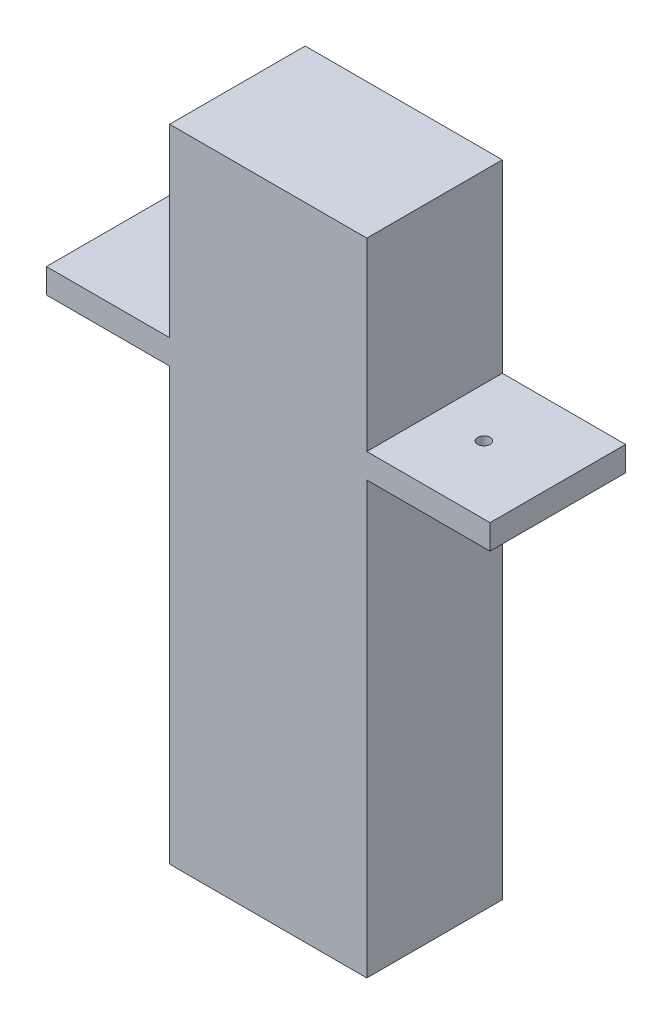
from build123d import *

# Parameters (mm, degrees)
BOSS_EXTRU_1_DEPTH      = 9
ESQUISSE2_W             = 16
ESQUISSE2_H             = 52
BOSS_EXTRU_2_DEPTH      = 2
ESQUISSE5_R             = 1.75
BOSS_EXTRU_5_DEPTH      = 5
ESQUISSE6_R             = 0.5
ENL_V_MAT_EXTRU_1_DEPTH = 5
ESQUISSE11_W            = 11
ESQUISSE11_H            = 2
BOSS_EXTRU_6_DEPTH      = 10
ESQUISSE12_R            = 0.5
ENL_V_MAT_EXTRU_2_DEPTH = 38


with BuildPart() as part:
    # Esquisse1 → Boss.-Extru.1 (new body)
    with BuildSketch(Plane.XY):
        Polygon((-6, -25), (-6, 25), (6, 25), (6, -25), (8, -25), (8, 27), (-8, 27), (-8, -25), align=None)
    extrude(amount=BOSS_EXTRU_1_DEPTH)

    # Esquisse2 → Boss.-Extru.2 (add)
    with BuildSketch(Plane.XY.offset(9)):
        with Locations((0, 1)):
            Rectangle(ESQUISSE2_W, ESQUISSE2_H)
    extrude(amount=BOSS_EXTRU_2_DEPTH)

    # Esquisse5 → Boss.-Extru.5 (add)
    with BuildSketch(Plane(origin=(0, 0, 9), x_dir=(-1, 0, 0), z_dir=(0, 0, -1))):
        with Locations((0, 4)):
            Circle(ESQUISSE5_R)
    extrude(amount=BOSS_EXTRU_5_DEPTH)

    # Esquisse6 → Enlèv. mat.-Extru.1 (cut)
    with BuildSketch(Plane(origin=(0, 0, 4), x_dir=(-1, 0, 0), z_dir=(0, 0, -1))):
        with Locations((0, 4)):
            Circle(ESQUISSE6_R)
    extrude(amount=-ENL_V_MAT_EXTRU_1_DEPTH, mode=Mode.SUBTRACT)

    # Esquisse11 → Boss.-Extru.6 (add)
    with BuildSketch(Plane.ZY.offset(8)):
        with Locations((5.5, 11)):
            Rectangle(ESQUISSE11_W, ESQUISSE11_H)
    boss_extru_6 = extrude(amount=BOSS_EXTRU_6_DEPTH)

    # Esquisse12 → Enlèv. mat.-Extru.2 (cut, through all)
    with BuildSketch(Plane(origin=(0, 12, 0), x_dir=(1, 0, 0), z_dir=(0, 1, 0))):
        with Locations((-12, -5.5)):
            Circle(ESQUISSE12_R)
    enl_v_mat_extru_2 = extrude(amount=-ENL_V_MAT_EXTRU_2_DEPTH, mode=Mode.SUBTRACT)

    # Symétrie1: Boss.-Extru.6, Enlèv. mat.-Extru.2 across plane
    add(boss_extru_6.mirror(Plane(origin=(0, 0, 0), x_dir=(0, 0, 1), z_dir=(1, 0, 0))))
    add(enl_v_mat_extru_2.mirror(Plane(origin=(0, 0, 0), x_dir=(0, 0, 1), z_dir=(1, 0, 0))), mode=Mode.SUBTRACT)


solid = part.part
